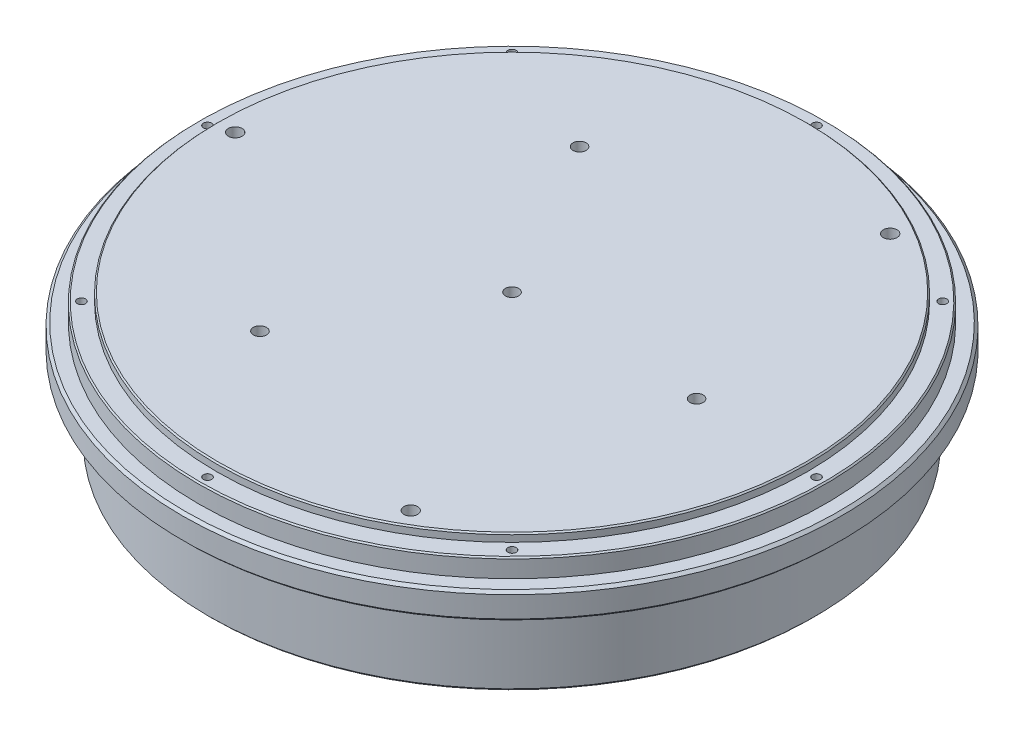
from build123d import *

# Parameters (mm, degrees)
SKETCH1_R                      = 125
BOSS_EXTRUDE1_DEPTH            = 50
SKETCH2_R                      = 127
SKETCH2_R_2                    = 119
PAKNING_DEPTH                  = 10
SKETCH3_R                      = 125
SKETCH3_R_2                    = 112
PAKNINGSRING_DEPTH             = 3
SKETCH7_R                      = 135
SKETCH7_R_2                    = 115
CUT_EXTRUDE6_DEPTH             = 30
CHAMFER2_SIZE                  = 0.5
CIRPATTERN2_COUNT              = 8
SKETCH19_R                     = 11
SPINDLE_DEPTH                  = 15.5
CIRPATTERN4_COUNT              = 3
F_10_0_10_DIAMETER_HOLE2_D     = 10
F_10_0_10_DIAMETER_HOLE2_DEPTH = 40.5
F_10_0_10_DIAMETER_HOLE2_TIP   = 3.004303095
F_5_0_5_DIAMETER_HOLE2_D       = 5
F_5_0_5_DIAMETER_HOLE2_DEPTH   = 10
F_5_0_5_DIAMETER_HOLE2_TIP     = 1.502151548
F_5_0_5_DIAMETER_HOLE3_D       = 5
F_5_0_5_DIAMETER_HOLE3_DEPTH   = 20.5
F_5_0_5_DIAMETER_HOLE3_TIP     = 1.502151548
M4_TAPPED_HOLE1_AT_2_COUNT     = 2
M4_TAPPED_HOLE1_AT_2_PITCH     = 19
M4_TAPPED_HOLE2_D              = 3.3
M4_TAPPED_HOLE2_DEPTH          = 10.1
M4_TAPPED_HOLE2_TIP            = 0.991420021
M4_TAPPED_HOLE3_D              = 3.3
M4_TAPPED_HOLE3_DEPTH          = 10.1
M4_TAPPED_HOLE3_TIP            = 0.991420021
CIRPATTERN8_COUNT              = 3
CIRPATTERN9_COUNT              = 3
CHAMFER3_SIZE                  = 1


with BuildPart() as part:
    # Sketch1 → Boss-Extrude1 (new body)
    with BuildSketch(Plane(origin=(0, 0, 0), x_dir=(1, 0, 0), z_dir=(0, 1, 0))):
        Circle(SKETCH1_R)
    extrude(amount=BOSS_EXTRUDE1_DEPTH)

    # Sketch2 → Pakning (cut)
    with BuildSketch(Plane(origin=(0, 50, 0), x_dir=(1, 0, 0), z_dir=(0, 1, 0))):
        Circle(SKETCH2_R)
        Circle(SKETCH2_R_2, mode=Mode.SUBTRACT)
    extrude(amount=-PAKNING_DEPTH, mode=Mode.SUBTRACT)

    # Sketch3 → PakningsRing (cut)
    with BuildSketch(Plane(origin=(0, 50, 0), x_dir=(1, 0, 0), z_dir=(0, 1, 0))):
        Circle(SKETCH3_R)
        Circle(SKETCH3_R_2, mode=Mode.SUBTRACT)
    extrude(amount=-PAKNINGSRING_DEPTH, mode=Mode.SUBTRACT)

    # Sketch7 → Cut-Extrude6 (cut)
    with BuildSketch(Plane.XZ):
        Circle(SKETCH7_R)
        Circle(SKETCH7_R_2, mode=Mode.SUBTRACT)
    extrude(amount=-CUT_EXTRUDE6_DEPTH, mode=Mode.SUBTRACT)

    # Chamfer2
    chamfer2_edges = [part.edges().sort_by_distance(p)[0] for p in [
        (-119, 47, 0),
        (-112, 50, 0),
    ]]
    chamfer(chamfer2_edges, length=CHAMFER2_SIZE)

    # Sketch17 → Tapped Hole for M3x0.5 Helicoil1 (revolve, cut)
    with BuildSketch(Plane(origin=(0, 47, -115.5), x_dir=(0, 0, 1), z_dir=(1, 0, 0))):
        Polygon((0, 0), (0, 5.946355475), (1.575, 5), (1.575, 0), align=None)
    tapped_hole_for_m3x0_5_helicoil1 = revolve(axis=Axis((0, 53.35, -115.5), (0, -1, 0)), mode=Mode.SUBTRACT)

    # CirPattern2: Tapped Hole for M3x0.5 Helicoil1 ×8 about axis
    cirpattern2_axis = Axis((0, 0, 0), (0, 1, 0))
    for i in range(1, CIRPATTERN2_COUNT):
        add(tapped_hole_for_m3x0_5_helicoil1.rotate(cirpattern2_axis, i * 360 / CIRPATTERN2_COUNT), mode=Mode.SUBTRACT)

    # Sketch19 → Spindle (cut)
    with BuildSketch(Plane.XZ):
        with Locations((-80, 0)):
            Circle(SKETCH19_R)
    spindle = extrude(amount=-SPINDLE_DEPTH, mode=Mode.SUBTRACT)

    # CirPattern4: Spindle ×3 about axis
    cirpattern4_axis = Axis((0, 0, 0), (0, 1, 0))
    for i in range(1, CIRPATTERN4_COUNT):
        add(spindle.rotate(cirpattern4_axis, i * 360 / CIRPATTERN4_COUNT), mode=Mode.SUBTRACT)

    # Sketch27 → Ø10.0 (10) Diameter Hole1 (revolve, cut)
    with BuildSketch(Plane(origin=(-35, 0, 60.621778265), x_dir=(0, 0, -1), z_dir=(1, 0, 0))):
        Polygon((0, 0), (0, 43.504303095), (5, 40.5), (5, 0), align=None)
    f_10_0_10_diameter_hole1 = revolve(axis=Axis((-35, -6.35, 60.621778265), (0, 1, 0)), mode=Mode.SUBTRACT)

    # Ø10.0 (10) Diameter Hole2
    with Locations(Plane(origin=(0, 0, 0), x_dir=(-1, 0, 0), z_dir=(0, -1, 0))):
        with Locations((0, 0)):
            Hole(F_10_0_10_DIAMETER_HOLE2_D / 2, depth=F_10_0_10_DIAMETER_HOLE2_DEPTH)
            with Locations((0, 0, -(F_10_0_10_DIAMETER_HOLE2_DEPTH + F_10_0_10_DIAMETER_HOLE2_TIP / 2))):  # 118° drill point
                Cone(0, F_10_0_10_DIAMETER_HOLE2_D / 2, F_10_0_10_DIAMETER_HOLE2_TIP, mode=Mode.SUBTRACT)

    # Sketch31 → Ø5.0 (5) Diameter Hole1 (revolve, cut)
    with BuildSketch(Plane(origin=(-35, 50, 60.621778265), x_dir=(0, 0, 1), z_dir=(1, 0, 0))):
        Polygon((0, 0), (0, 11.502151548), (2.5, 10), (2.5, 0), align=None)
    f_5_0_5_diameter_hole1 = revolve(axis=Axis((-35, 56.35, 60.621778265), (0, -1, 0)), mode=Mode.SUBTRACT)

    # Ø5.0 (5) Diameter Hole2
    with Locations(Plane(origin=(0, 50, 0), x_dir=(1, 0, 0), z_dir=(0, 1, 0))):
        with Locations((0, 0)):
            Hole(F_5_0_5_DIAMETER_HOLE2_D / 2, depth=F_5_0_5_DIAMETER_HOLE2_DEPTH)
            with Locations((0, 0, -(F_5_0_5_DIAMETER_HOLE2_DEPTH + F_5_0_5_DIAMETER_HOLE2_TIP / 2))):  # 118° drill point
                Cone(0, F_5_0_5_DIAMETER_HOLE2_D / 2, F_5_0_5_DIAMETER_HOLE2_TIP, mode=Mode.SUBTRACT)

    # Ø5.0 (5) Diameter Hole3
    with Locations(Plane(origin=(0, 0, 0), x_dir=(-1, 0, 0), z_dir=(0, -1, 0))):
        with Locations((-20, -34.641016151)):
            Hole(F_5_0_5_DIAMETER_HOLE3_D / 2, depth=F_5_0_5_DIAMETER_HOLE3_DEPTH)
            with Locations((0, 0, -(F_5_0_5_DIAMETER_HOLE3_DEPTH + F_5_0_5_DIAMETER_HOLE3_TIP / 2))):  # 118° drill point
                Cone(0, F_5_0_5_DIAMETER_HOLE3_D / 2, F_5_0_5_DIAMETER_HOLE3_TIP, mode=Mode.SUBTRACT)

    # Sketch37 → M4 Tapped Hole1 (revolve, cut)
    with BuildSketch(Plane(origin=(-43.227241336, 0, 55.871778265), x_dir=(0, 0, -1), z_dir=(1, 0, 0))):
        Polygon((0, 0), (0, 11.091420021), (1.65, 10.1), (1.65, 0), align=None)
    m4_tapped_hole1 = revolve(axis=Axis((-43.227241336, -6.35, 55.871778265), (0, 1, 0)), mode=Mode.SUBTRACT)

    # M4 Tapped Hole1 at 2: M4 Tapped Hole1 ×2
    with Locations(*[Vector(0.866025404, 0, 0.5) * (i * M4_TAPPED_HOLE1_AT_2_PITCH) for i in range(1, M4_TAPPED_HOLE1_AT_2_COUNT)]):
        add(m4_tapped_hole1, mode=Mode.SUBTRACT)

    # M4 Tapped Hole2
    with Locations(Plane(origin=(0, 0, 0), x_dir=(-1, 0, 0), z_dir=(0, -1, 0))):
        with Locations((8.227241336, -4.75), (-8.227241336, 4.75)):
            Hole(M4_TAPPED_HOLE2_D / 2, depth=M4_TAPPED_HOLE2_DEPTH)
            with Locations((0, 0, -(M4_TAPPED_HOLE2_DEPTH + M4_TAPPED_HOLE2_TIP / 2))):  # 118° drill point
                Cone(0, M4_TAPPED_HOLE2_D / 2, M4_TAPPED_HOLE2_TIP, mode=Mode.SUBTRACT)

    # M4 Tapped Hole3
    with Locations(Plane(origin=(0, 0, 0), x_dir=(-1, 0, 0), z_dir=(0, -1, 0))):
        with Locations((-13.504809472, -38.391016151), (-26.495190528, -30.891016151)):
            Hole(M4_TAPPED_HOLE3_D / 2, depth=M4_TAPPED_HOLE3_DEPTH)
            with Locations((0, 0, -(M4_TAPPED_HOLE3_DEPTH + M4_TAPPED_HOLE3_TIP / 2))):  # 118° drill point
                Cone(0, M4_TAPPED_HOLE3_D / 2, M4_TAPPED_HOLE3_TIP, mode=Mode.SUBTRACT)

    # Sketch43 → Tapped Hole for M5x0.8 Helicoil1 (revolve, cut)
    with BuildSketch(Plane(origin=(52.5, 50, -90.932667397), x_dir=(0, 0, 1), z_dir=(1, 0, 0))):
        Polygon((0, 0), (0, 9.762237609), (2.6, 8.2), (2.6, 0), align=None)
    tapped_hole_for_m5x0_8_helicoil1 = revolve(axis=Axis((52.5, 56.35, -90.932667397), (0, -1, 0)), mode=Mode.SUBTRACT)

    # CirPattern8: Tapped Hole for M5x0.8 Helicoil1 ×3 about axis
    cirpattern8_axis = Axis((0, 0, 0), (0, 1, 0))
    for i in range(1, CIRPATTERN8_COUNT):
        add(tapped_hole_for_m5x0_8_helicoil1.rotate(cirpattern8_axis, i * 360 / CIRPATTERN8_COUNT), mode=Mode.SUBTRACT)

    # CirPattern9: Ø10.0 (10) Diameter Hole1, M4 Tapped Hole1, Ø5.0 (5) Diameter Hole1 ×3 about axis
    cirpattern9_axis = Axis((0, 0, 0), (0, 1, 0))
    for i in range(1, CIRPATTERN9_COUNT):
        add(f_10_0_10_diameter_hole1.rotate(cirpattern9_axis, i * 360 / CIRPATTERN9_COUNT), mode=Mode.SUBTRACT)
        add(m4_tapped_hole1.rotate(cirpattern9_axis, i * 360 / CIRPATTERN9_COUNT), mode=Mode.SUBTRACT)
        add(f_5_0_5_diameter_hole1.rotate(cirpattern9_axis, i * 360 / CIRPATTERN9_COUNT), mode=Mode.SUBTRACT)

    # CirPattern9 copy 1 sketch → CirPattern9 copy 1 (revolve, cut)
    with BuildSketch(Plane(origin=(70, 0, -9.5), x_dir=(-0.866025404, 0, 0.5), z_dir=(-0.5, 0, -0.866025404))):
        Polygon((0, 0), (0, 11.091420021), (1.65, 10.1), (1.65, 0), align=None)
    revolve(axis=Axis((70, -6.35, -9.5), (0, 1, 0)), mode=Mode.SUBTRACT)

    # CirPattern9 copy 2 sketch → CirPattern9 copy 2 (revolve, cut)
    with BuildSketch(Plane(origin=(-43.227241336, 0, -55.871778265), x_dir=(0.866025404, 0, 0.5), z_dir=(-0.5, 0, 0.866025404))):
        Polygon((0, 0), (0, 11.091420021), (1.65, 10.1), (1.65, 0), align=None)
    revolve(axis=Axis((-43.227241336, -6.35, -55.871778265), (0, 1, 0)), mode=Mode.SUBTRACT)

    # Chamfer3
    chamfer3_edges = [part.edges().sort_by_distance(p)[0] for p in [
        (-125, 30, 0),
        (-115, 0, 0),
        (-125, 40, 0),
    ]]
    chamfer(chamfer3_edges, length=CHAMFER3_SIZE)


solid = part.part
